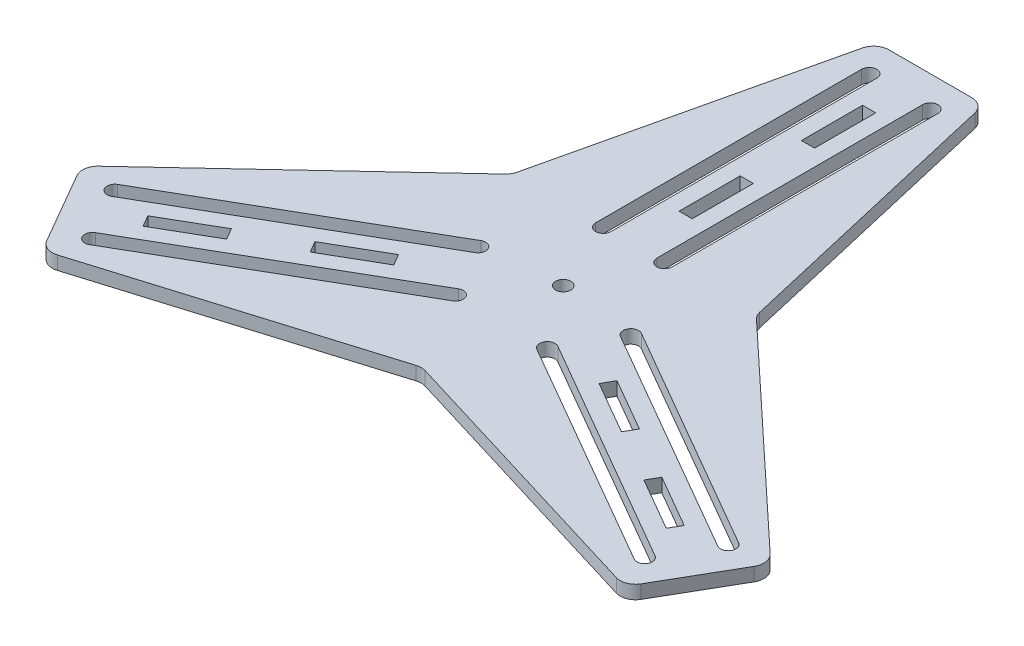
from build123d import *

# Parameters (mm, degrees)
SKETCH1_W           = 5.461
SKETCH1_H           = 25.4
BOSS_EXTRUDE1_DEPTH = 5.588
CIRPATTERN1_COUNT   = 3
SKETCH3_R           = 3.175
CUT_EXTRUDE1_DEPTH  = 6.588
FILLET2_R           = 6.35


with BuildPart() as part:
    # Sketch1 → Boss-Extrude1 (new body)
    with BuildSketch(Plane(origin=(0, 0, 0), x_dir=(1, 0, 0), z_dir=(0, 1, 0))):
        Polygon((0, 0), (50.8, 29.329393675), (22.225, 152.4), (-22.225, 152.4), (-50.8, 29.329393675), align=None)
        with BuildLine():
            Line((-9.525, 29.329393675), (-9.525, 139.7))
            ThreePointArc((-9.525, 139.7), (-12.7, 142.875), (-15.875, 139.7))
            Line((-15.875, 139.7), (-15.875, 29.329393675))
            ThreePointArc((-15.875, 29.329393675), (-12.7, 26.154393675), (-9.525, 29.329393675))
        make_face(mode=Mode.SUBTRACT)
        with Locations((0, 63.5)):
            Rectangle(SKETCH1_W, SKETCH1_H, mode=Mode.SUBTRACT)
        with BuildLine():
            Line((9.525, 29.329393675), (9.525, 139.7))
            ThreePointArc((9.525, 139.7), (12.7, 142.875), (15.875, 139.7))
            Line((15.875, 139.7), (15.875, 29.329393675))
            ThreePointArc((15.875, 29.329393675), (12.7, 26.154393675), (9.525, 29.329393675))
        make_face(mode=Mode.SUBTRACT)
        with Locations((0, 114.3)):
            Rectangle(SKETCH1_W, SKETCH1_H, mode=Mode.SUBTRACT)
    boss_extrude1 = extrude(amount=BOSS_EXTRUDE1_DEPTH)

    # CirPattern1: Boss-Extrude1 ×3 about axis
    cirpattern1_axis = Axis((0, 0, 0), (0, 1, 0))
    for i in range(1, CIRPATTERN1_COUNT):
        add(boss_extrude1.rotate(cirpattern1_axis, i * 360 / CIRPATTERN1_COUNT))

    # Sketch3 → Cut-Extrude1 (cut, through all)
    with BuildSketch(Plane(origin=(0, 5.588, 0), x_dir=(1, 0, 0), z_dir=(0, 1, 0))):
        Circle(SKETCH3_R)
    extrude(amount=-CUT_EXTRUDE1_DEPTH, mode=Mode.SUBTRACT)

    # Fillet2
    fillet2_edges = [part.edges().sort_by_distance(p)[0] for p in [
        (-143.094771537, 2.794, 56.952585401),
        (-120.869771537, 2.794, 95.447414599),
        (-50.8, 2.794, -29.329393675),
        (-22.225, 2.794, -152.4),
        (22.225, 2.794, -152.4),
        (50.8, 2.794, -29.329393675),
        (0, 2.794, 58.65878735),
        (120.869771537, 2.794, 95.447414599),
        (143.094771537, 2.794, 56.952585401),
    ]]
    fillet(fillet2_edges, radius=FILLET2_R)


solid = part.part
